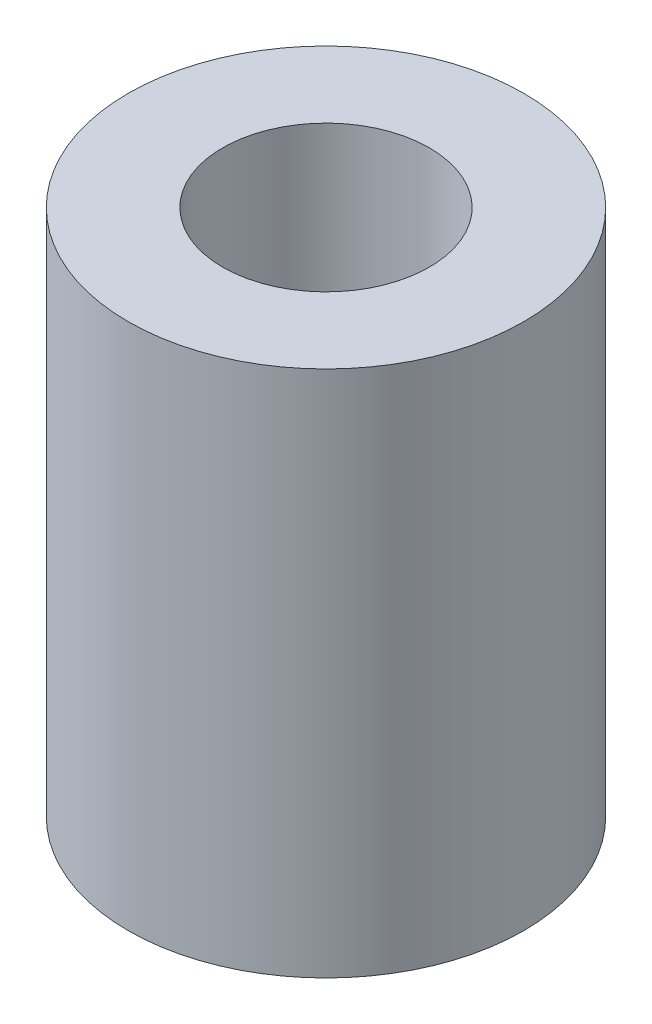
from build123d import *

# Parameters (mm, degrees)
SKETCH1_R           = 4.7625
SKETCH1_R_2         = 2.4892
BOSS_EXTRUDE1_DEPTH = 6.35


with BuildPart() as part:
    # Sketch1 → Boss-Extrude1 (new body, symmetric)
    with BuildSketch(Plane(origin=(0, 0, 0), x_dir=(1, 0, 0), z_dir=(0, 1, 0))):
        Circle(SKETCH1_R)
        Circle(SKETCH1_R_2, mode=Mode.SUBTRACT)
    extrude(amount=BOSS_EXTRUDE1_DEPTH, both=True)


solid = part.part
